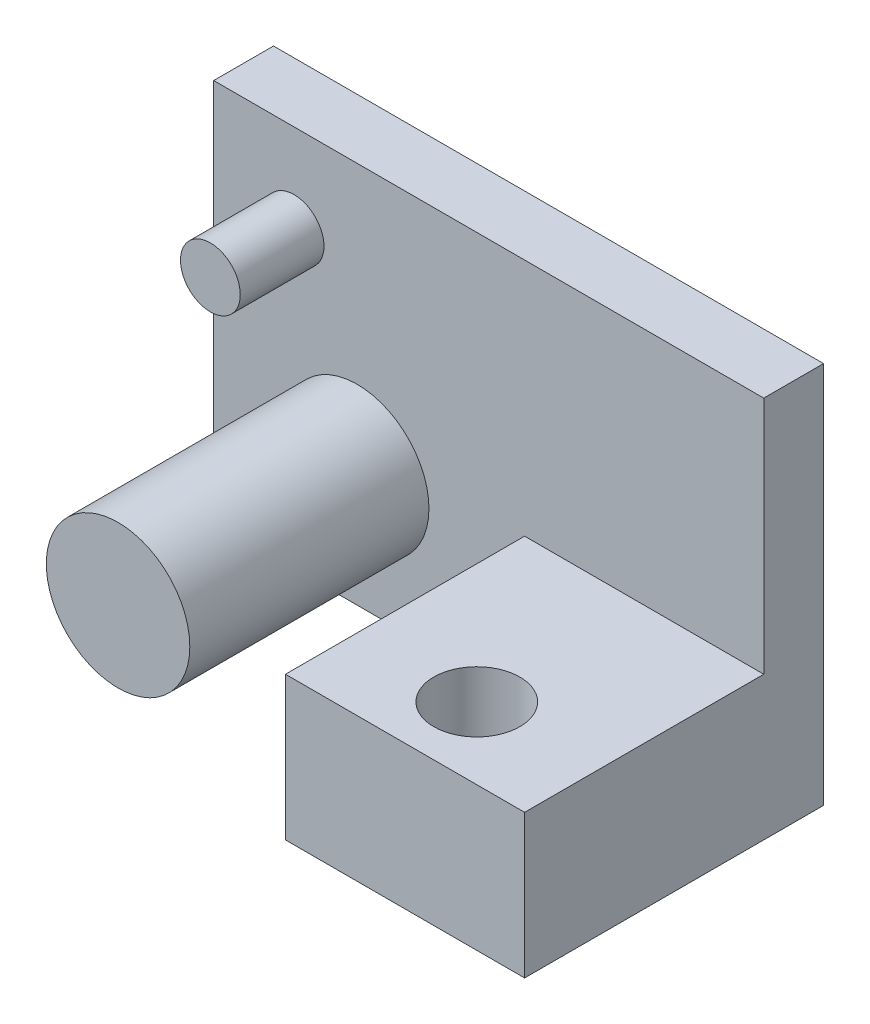
from build123d import *

# Parameters (mm, degrees)
BOSS_EXTRUDE1_DEPTH = 2.5
SKETCH2_R           = 1.25
BOSS_EXTRUDE2_DEPTH = 3.5
SKETCH3_R           = 3
BOSS_EXTRUDE3_DEPTH = 10
SKETCH4_W           = 10
SKETCH4_H           = 6
BOSS_EXTRUDE4_DEPTH = 10
SKETCH5_R           = 1.8
CUT_EXTRUDE1_DEPTH  = 10
BOSS_EXTRUDE5_DEPTH = 2.5
SKETCH9_W           = 7
SKETCH9_H           = 30
CUT_EXTRUDE2_DEPTH  = 10
SKETCH10_W          = 15.6
SKETCH10_H          = 14
CUT_EXTRUDE3_DEPTH  = 10
SKETCH11_W          = 2
SKETCH11_H          = 16
CUT_EXTRUDE4_DEPTH  = 10
SKETCH12_R          = 1.25
BOSS_EXTRUDE6_DEPTH = 3.5
SKETCH13_W          = 2
SKETCH13_H          = 3
CUT_EXTRUDE5_DEPTH  = 10


with BuildPart() as part:
    # Sketch1 → Boss-Extrude1 (new body)
    with BuildSketch(Plane.XY):
        Polygon((-35.69030782, -28.289725458), (-35.69030782, -18.289725458), (-17.69030782, 1.710274542), (-7.69030782, 1.710274542), (-7.69030782, -28.289725458), align=None)
    extrude(amount=BOSS_EXTRUDE1_DEPTH)

    # Sketch2 → Boss-Extrude2 (add)
    with BuildSketch(Plane.XY.offset(2.5)):
        with Locations((-11.69030782, -2.669725458)):
            Circle(SKETCH2_R)
    extrude(amount=BOSS_EXTRUDE2_DEPTH)

    # Sketch3 → Boss-Extrude3 (add)
    with BuildSketch(Plane.XY.offset(2.5)):
        with Locations((-31.69030782, -23.289725458)):
            Circle(SKETCH3_R)
    extrude(amount=BOSS_EXTRUDE3_DEPTH)

    # Sketch4 → Boss-Extrude4 (add)
    with BuildSketch(Plane.XY.offset(2.5)):
        with Locations((-19.69030782, -25.289725458)):
            Rectangle(SKETCH4_W, SKETCH4_H)
    extrude(amount=BOSS_EXTRUDE4_DEPTH)

    # Sketch5 → Cut-Extrude1 (cut)
    with BuildSketch(Plane(origin=(0, -22.289725458, 0), x_dir=(1, 0, 0), z_dir=(0, 1, 0))):
        with Locations((-19.69030782, -9.5)):
            Circle(SKETCH5_R)
    extrude(amount=-CUT_EXTRUDE1_DEPTH, mode=Mode.SUBTRACT)

    # Sketch6 → Boss-Extrude5 (add)
    with BuildSketch(Plane.XY.offset(2.5)):
        Polygon((-35.69030782, -28.289725458), (-39.69030782, -28.289725458), (-39.69030782, -12.289725458), (-30.29030782, -12.289725458), (-35.69030782, -18.289725458), align=None)
    extrude(amount=-BOSS_EXTRUDE5_DEPTH)

    # Sketch9 → Cut-Extrude2 (cut)
    with BuildSketch(Plane.XY.offset(6)):
        with Locations((-11.19030782, -13.289725458)):
            Rectangle(SKETCH9_W, SKETCH9_H)
    extrude(amount=-CUT_EXTRUDE2_DEPTH, mode=Mode.SUBTRACT)

    # Sketch10 → Cut-Extrude3 (cut)
    with BuildSketch(Plane.XY.offset(2.5)):
        with Locations((-22.49030782, -5.289725458)):
            Rectangle(SKETCH10_W, SKETCH10_H)
    extrude(amount=-CUT_EXTRUDE3_DEPTH, mode=Mode.SUBTRACT)

    # Sketch11 → Cut-Extrude4 (cut)
    with BuildSketch(Plane.XY.offset(2.5)):
        with Locations((-38.69030782, -20.289725458)):
            Rectangle(SKETCH11_W, SKETCH11_H)
    extrude(amount=-CUT_EXTRUDE4_DEPTH, mode=Mode.SUBTRACT)

    # Sketch12 → Boss-Extrude6 (add)
    with BuildSketch(Plane.XY.offset(2.5)):
        with Locations((-34.33030782, -15.989725458)):
            Circle(SKETCH12_R)
    extrude(amount=BOSS_EXTRUDE6_DEPTH)

    # Sketch13 → Cut-Extrude5 (cut)
    with BuildSketch(Plane.XY.offset(2.5)):
        with Locations((-36.69030782, -26.789725458)):
            Rectangle(SKETCH13_W, SKETCH13_H)
    extrude(amount=-CUT_EXTRUDE5_DEPTH, mode=Mode.SUBTRACT)


solid = part.part
